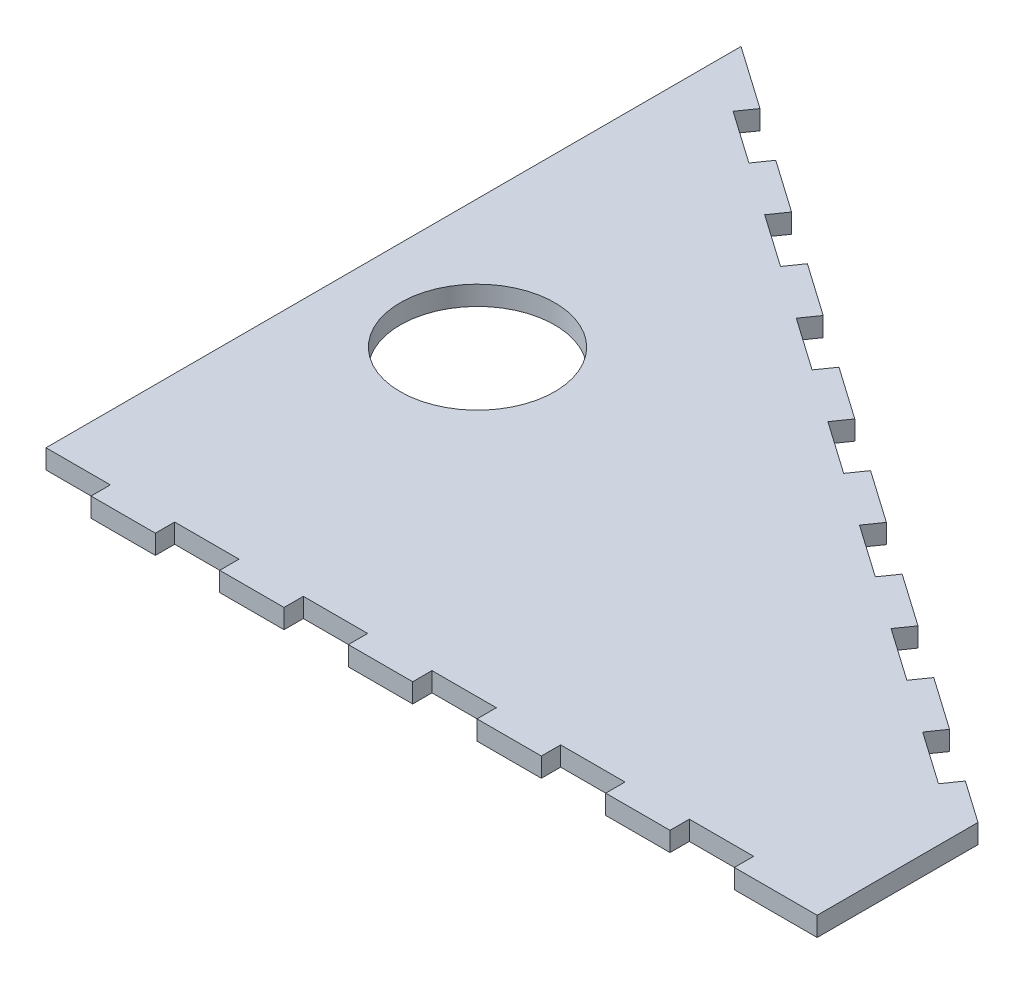
from build123d import *

# Parameters (mm, degrees)
ESQUISSE1_R        = 12
BOSS_EXTRU_1_DEPTH = 3


with BuildPart() as part:
    # Esquisse1 → Boss.-Extru.1 (new body)
    with BuildSketch(Plane(origin=(0, 0, 0), x_dir=(1, 0, 0), z_dir=(0, 1, 0))):
        Polygon((0, 0), (0, 86.036465453), (9.829824531, 79.153548216), (8.109095222, 76.696092084), (16.300615665, 70.96032772), (18.021344974, 73.417783853), (26.212865417, 67.682019489), (24.492136108, 65.224563357), (32.683656551, 59.488798993), (34.40438586, 61.946255126), (42.595906303, 56.210490762), (40.875176994, 53.75303463), (49.066697437, 48.017270266), (50.787426746, 50.474726399), (58.978947189, 44.738962035), (57.25821788, 42.281505903), (65.449738323, 36.545741539), (67.170467632, 39.003197672), (75.361988075, 33.267433308), (73.641258766, 30.809977175), (81.832779208, 25.074212812), (83.553508517, 27.531668945), (91.74502896, 21.795904581), (90.024299651, 19.338448448), (98.215820094, 13.602684085), (99.936549403, 16.060140218), (108.128069846, 10.324375854), (106.407340537, 7.866919721), (114.59886098, 2.131155358), (116.319590289, 4.588611491), (122.872806643, 0), (122.872806643, -25), (110, -25), (110, -22), (100, -22), (100, -25), (90, -25), (90, -22), (80, -22), (80, -25), (70, -25), (70, -22), (60, -22), (60, -25), (50, -25), (50, -22), (40, -22), (40, -25), (30, -25), (30, -22), (20, -22), (20, -25), (10, -25), (10, -22), (0, -22), align=None)
        with Locations((20, 25.074212812)):
            Circle(ESQUISSE1_R, mode=Mode.SUBTRACT)
    extrude(amount=BOSS_EXTRU_1_DEPTH)


solid = part.part
